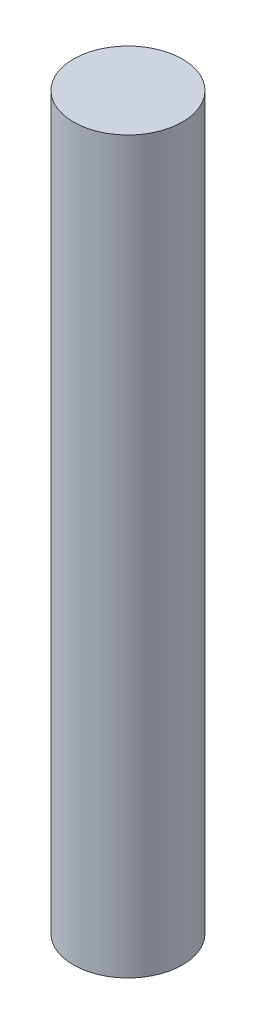
from build123d import *

# Parameters (mm, degrees)
SKETCH1_R           = 3
BOSS_EXTRUDE1_DEPTH = 40.175


with BuildPart() as part:
    # Sketch1 → Boss-Extrude1 (new body)
    with BuildSketch(Plane(origin=(0, 0, 0), x_dir=(1, 0, 0), z_dir=(0, 1, 0))):
        Circle(SKETCH1_R)
    extrude(amount=BOSS_EXTRUDE1_DEPTH)


solid = part.part
